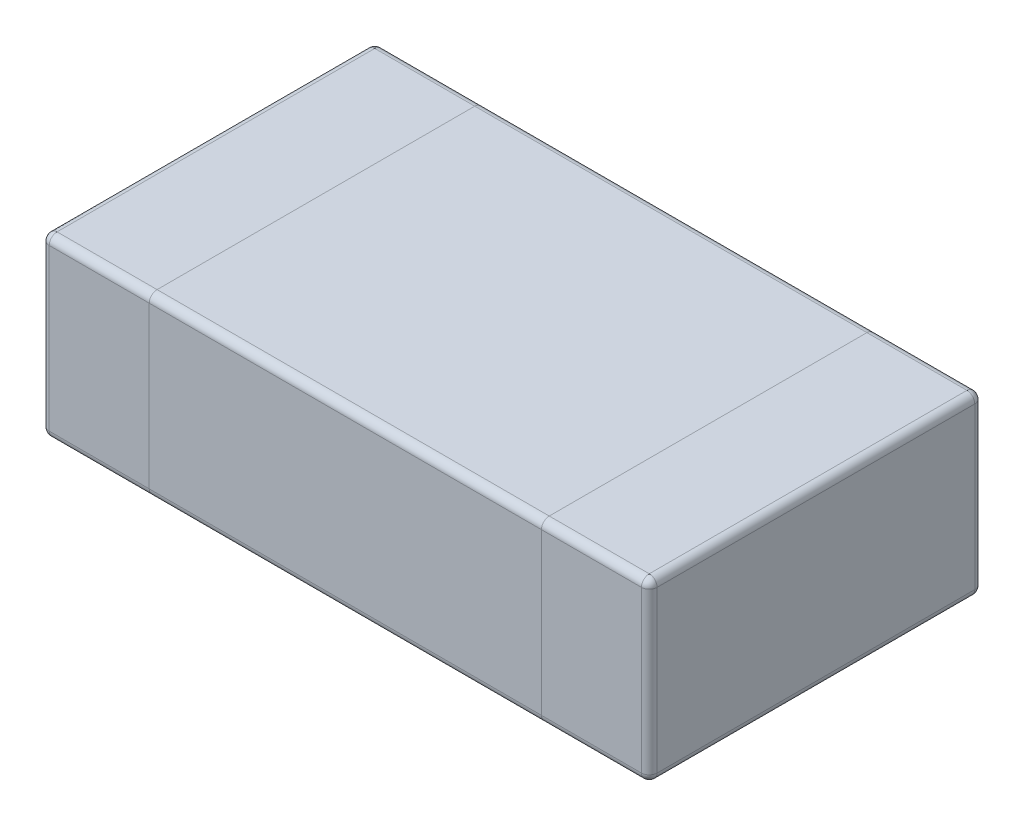
from build123d import *

# Parameters (mm, degrees)
BOSS_EXTRUDE1_DEPTH = 0.225
FILLET2_R           = 0.02


with BuildPart() as part:
    # Sketch1 → Boss-Extrude1 (new body, symmetric)
    with BuildSketch(Plane(origin=(0, 0, 0), x_dir=(1, 0, 0), z_dir=(0, 1, 0))):
        with BuildLine():
            Line((-0.755, -0.425), (0.755, -0.425))
            ThreePointArc((0.755, -0.425), (0.769142136, -0.419142136), (0.775, -0.405))
            Line((0.775, -0.405), (0.775, 0.405))
            ThreePointArc((0.775, 0.405), (0.769142136, 0.419142136), (0.755, 0.425))
            Line((0.755, 0.425), (-0.755, 0.425))
            ThreePointArc((-0.755, 0.425), (-0.769142136, 0.419142136), (-0.775, 0.405))
            Line((-0.775, 0.405), (-0.775, -0.405))
            ThreePointArc((-0.775, -0.405), (-0.769142136, -0.419142136), (-0.755, -0.425))
        make_face()
    extrude(amount=BOSS_EXTRUDE1_DEPTH, both=True)

    # Fillet2
    fillet2_edges = [part.edges().sort_by_distance(p)[0] for p in [
        (0.769142136, 0.225, 0.419142136),
        (0, -0.225, 0.425),
        (-0.769142136, -0.225, 0.419142136),
        (0.775, 0.225, 0),
        (0.769142136, 0.225, -0.419142136),
        (0, 0.225, -0.425),
        (-0.769142136, 0.225, -0.419142136),
        (-0.775, 0.225, 0),
        (0, 0.225, 0.425),
        (0, 0.225, -0.425),
        (0, 0.225, -0.425),
        (0, 0.225, 0.425),
        (0, -0.225, 0.425),
        (0, -0.225, 0.425),
        (0, -0.225, -0.425),
        (0, -0.225, -0.425),
        (-0.769142136, 0.225, 0.419142136),
        (0, 0.225, 0.425),
        (-0.775, -0.225, 0),
        (-0.769142136, -0.225, -0.419142136),
        (0, -0.225, -0.425),
        (0.769142136, -0.225, -0.419142136),
        (0.775, -0.225, 0),
        (0.769142136, -0.225, 0.419142136),
    ]]
    fillet(fillet2_edges, radius=FILLET2_R)


solid = part.part
